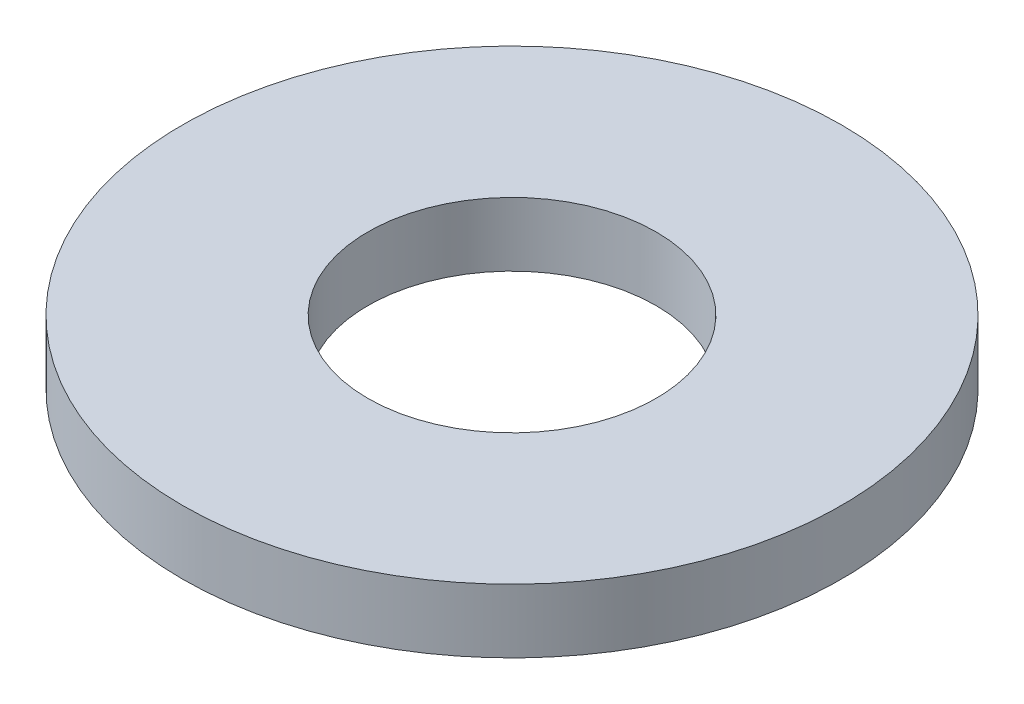
from build123d import *

# Parameters (mm, degrees)
SKETCH1_W = 4.572
SKETCH1_H = 1.5748


with BuildPart() as part:
    # Sketch1 → Revolve1 (revolve)
    with BuildSketch(Plane.XY):
        with Locations((5.842, -0.7874)):
            Rectangle(SKETCH1_W, SKETCH1_H)
    revolve(axis=Axis((0, 0, 0), (0, -1, 0)))


solid = part.part
